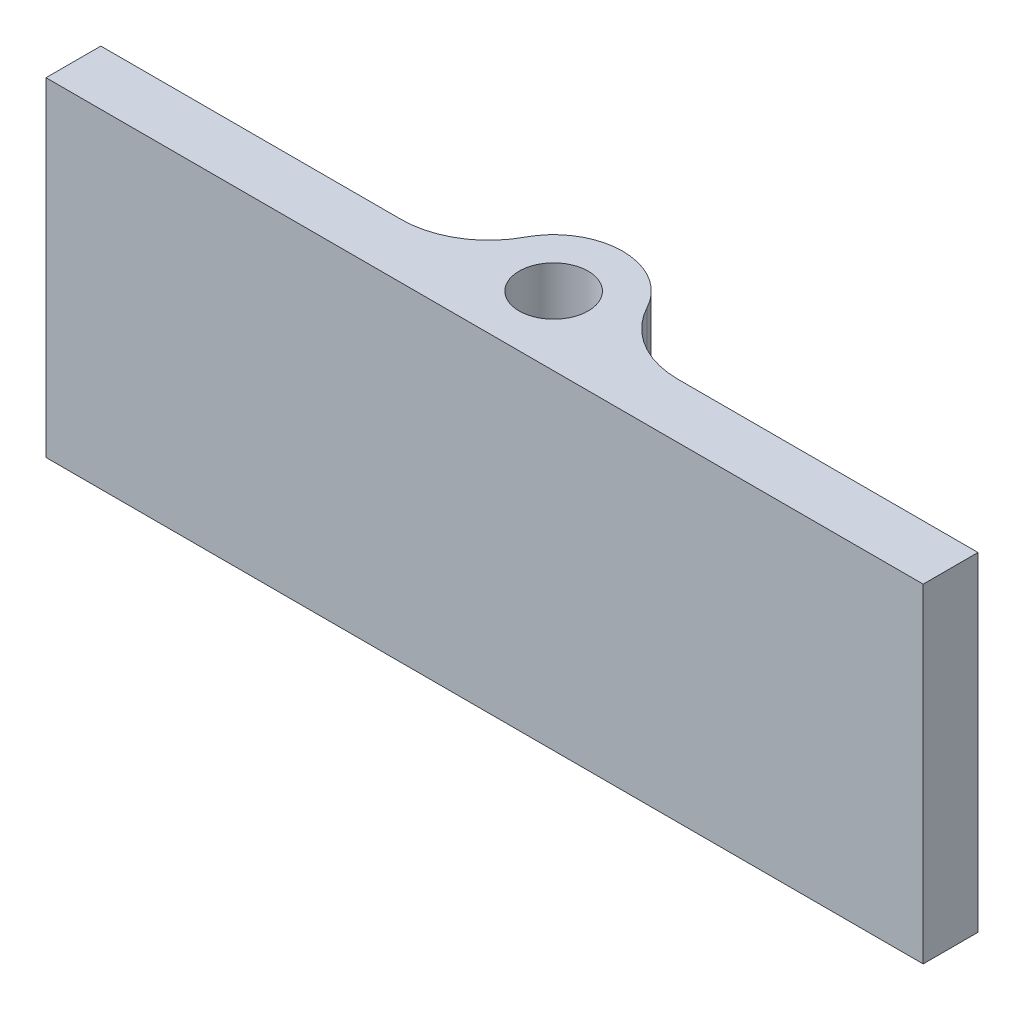
from build123d import *

# Parameters (mm, degrees)
SKETCH1_R           = 1
BOSS_EXTRUDE1_DEPTH = 9.525
FILLET1_R           = 2.54


with BuildPart() as part:
    # Sketch1 → Boss-Extrude1 (new body)
    with BuildSketch(Plane(origin=(0, 0, 0), x_dir=(1, 0, 0), z_dir=(0, 1, 0))):
        with BuildLine():
            Line((-12.7, -0.4125), (-12.7, -2))
            Line((-12.7, -2), (12.7, -2))
            Line((12.7, -2), (12.7, -0.4125))
            Line((12.7, -0.4125), (1.956998659, -0.4125))
            ThreePointArc((1.956998659, -0.4125), (0, 2), (-1.956998659, -0.4125))
            Line((-1.956998659, -0.4125), (-12.7, -0.4125))
        make_face()
        Circle(SKETCH1_R, mode=Mode.SUBTRACT)
    extrude(amount=BOSS_EXTRUDE1_DEPTH)

    # Fillet1
    fillet1_edges = [part.edges().sort_by_distance(p)[0] for p in [
        (-1.956998659, 4.7625, 0.4125),
        (1.956998659, 4.7625, 0.4125),
    ]]
    fillet(fillet1_edges, radius=FILLET1_R)


solid = part.part
